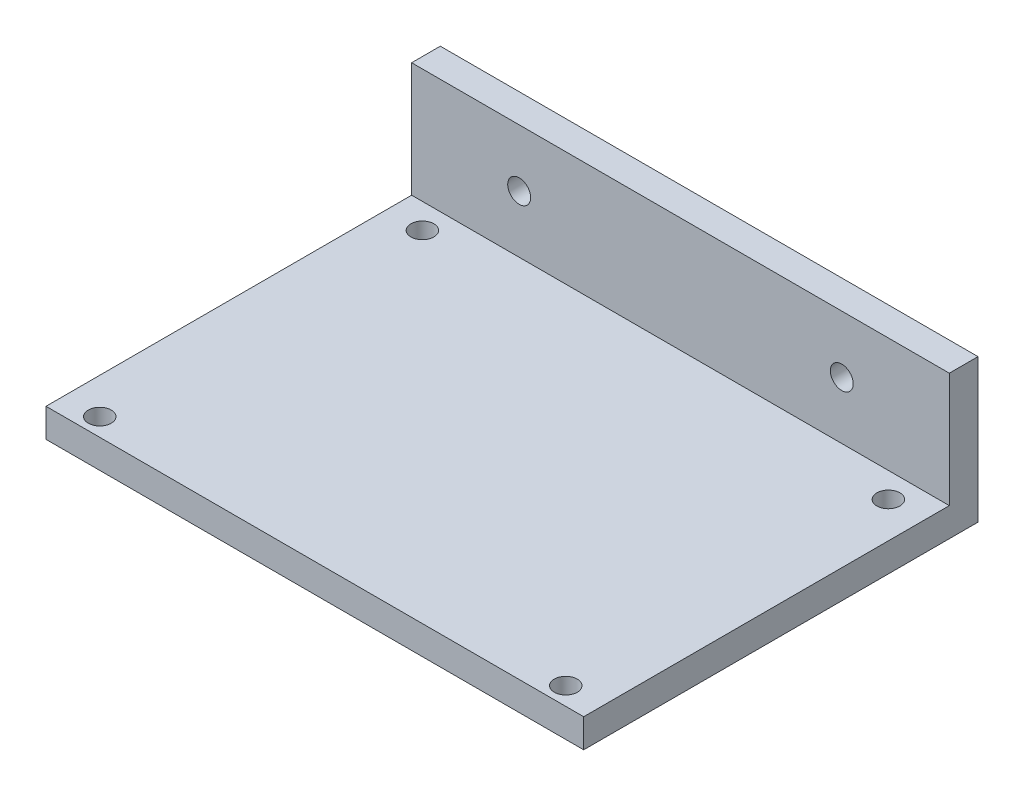
from build123d import *

# Parameters (mm, degrees)
SKETCH1_W           = 75
SKETCH1_H           = 55
BOSS_EXTRUDE1_DEPTH = 20
SKETCH2_W           = 51
SKETCH2_H           = 16
CUT_EXTRUDE1_DEPTH  = 94
SKETCH3_R           = 1.6
CUT_EXTRUDE2_DEPTH  = 54
SKETCH4_R           = 1.6
CUT_EXTRUDE3_DEPTH  = 10


with BuildPart() as part:
    # Sketch1 → Boss-Extrude1 (new body)
    with BuildSketch(Plane(origin=(0, 0, 0), x_dir=(1, 0, 0), z_dir=(0, 1, 0))):
        with Locations((37.5, 27.5)):
            Rectangle(SKETCH1_W, SKETCH1_H)
    extrude(amount=BOSS_EXTRUDE1_DEPTH)

    # Sketch2 → Cut-Extrude1 (cut)
    with BuildSketch(Plane(origin=(75, 0, 0), x_dir=(0, 0, -1), z_dir=(1, 0, 0))):
        with Locations((25.5, 12)):
            Rectangle(SKETCH2_W, SKETCH2_H)
    extrude(amount=-CUT_EXTRUDE1_DEPTH, mode=Mode.SUBTRACT)

    # Sketch3 → Cut-Extrude2 (cut)
    with BuildSketch(Plane(origin=(0, 0, -55), x_dir=(-1, 0, 0), z_dir=(0, 0, -1))):
        with Locations((-60, 12)):
            Circle(SKETCH3_R)
        with Locations((-15, 12)):
            Circle(SKETCH3_R)
    extrude(amount=-CUT_EXTRUDE2_DEPTH, mode=Mode.SUBTRACT)

    # Sketch4 → Cut-Extrude3 (cut)
    with BuildSketch(Plane.XZ):
        with Locations((5, -2.5)):
            Circle(SKETCH4_R)
        with Locations((5, -47.5)):
            Circle(SKETCH4_R)
        with Locations((70, -47.5)):
            Circle(SKETCH4_R)
        with Locations((70, -2.5)):
            Circle(SKETCH4_R)
    extrude(amount=-CUT_EXTRUDE3_DEPTH, mode=Mode.SUBTRACT)


solid = part.part
